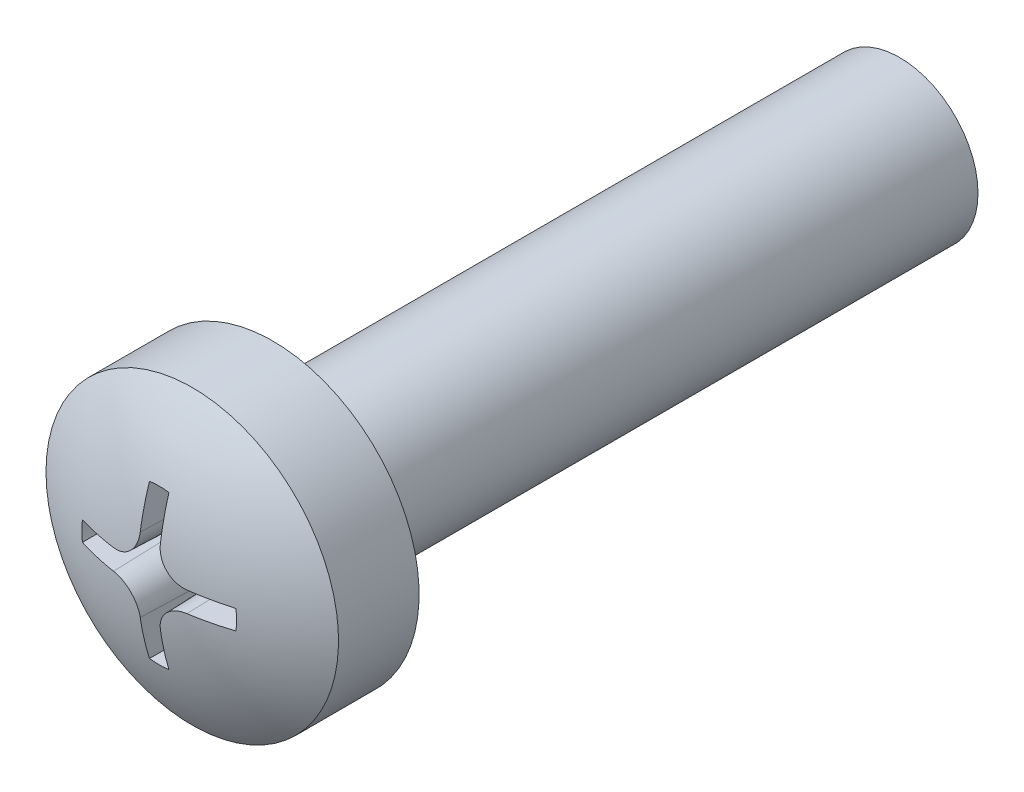
from build123d import *

# Parameters (mm, degrees)
SKETCH1_R               = 1.5
BASE_EXTRUDE_DEPTH      = 12
BASE_EXTRUDE_DEPTH_BACK = 0.0001
CUT_EXTRUDE1_DEPTH      = 1.799999969
CUT_EXTRUDE1_TAPER      = 2


with BuildPart() as part:
    # Sketch1 → Base-Extrude (new body, two sides)
    with BuildSketch(Plane.XY) as base_extrude_sk:
        Circle(SKETCH1_R)
    extrude(amount=BASE_EXTRUDE_DEPTH)
    extrude(base_extrude_sk.sketch, amount=-BASE_EXTRUDE_DEPTH_BACK)

    # Sketch6 → Boss-Revolve2 (revolve)
    with BuildSketch(Plane(origin=(0, 0, 0), x_dir=(1, 0, 0), z_dir=(0, 1, 0))):
        with BuildLine():
            Line((0, -12), (2.7999999, -12))
            Line((2.7999999, -12), (2.7999999, -13.54246308))
            ThreePointArc((2.7999999, -13.54246308), (1.46418655, -14.180811406), (0, -14.4))
            Line((0, -14.4), (0, -12))
        make_face()
    revolve(axis=Axis((0, 0, -0.393620135), (0, 0, 1)))

    # Sketch7 → Cut-Extrude1 (cut)
    with BuildSketch(Plane(origin=(0, 0, 14.7000001), x_dir=(-1, 0, 0), z_dir=(0, 0, -1))):
        with BuildLine():
            ThreePointArc((0.205000004, 1.48592565), (0, 1.500000013), (-0.205000004, 1.48592565))
            Line((-0.205000004, 1.48592565), (-0.205000004, 0.708178558))
            ThreePointArc((-0.205000004, 0.708178558), (-0.35072876, 0.355344481), (-0.702967546, 0.208182689))
            Line((-0.702967546, 0.208182689), (-1.48592565, 0.205000004))
            ThreePointArc((-1.48592565, 0.205000004), (-1.500000013, 0), (-1.48592565, -0.205000004))
            Line((-1.48592565, -0.205000004), (-0.702967546, -0.208182689))
            ThreePointArc((-0.702967546, -0.208182689), (-0.35072876, -0.355344481), (-0.205000004, -0.708178558))
            Line((-0.205000004, -0.708178558), (-0.205000004, -1.48592565))
            ThreePointArc((-0.205000004, -1.48592565), (0, -1.500000013), (0.205000004, -1.48592565))
            Line((0.205000004, -1.48592565), (0.205000004, -0.708178558))
            ThreePointArc((0.205000004, -0.708178558), (0.35072876, -0.355344481), (0.702967546, -0.208182689))
            Line((0.702967546, -0.208182689), (1.48592565, -0.205000004))
            ThreePointArc((1.48592565, -0.205000004), (1.500000013, 0), (1.48592565, 0.205000004))
            Line((1.48592565, 0.205000004), (0.702967546, 0.208182689))
            ThreePointArc((0.702967546, 0.208182689), (0.35072876, 0.355344481), (0.205000004, 0.708178558))
            Line((0.205000004, 0.708178558), (0.205000004, 1.48592565))
        make_face()
    extrude(amount=CUT_EXTRUDE1_DEPTH, taper=CUT_EXTRUDE1_TAPER, mode=Mode.SUBTRACT)


solid = part.part
